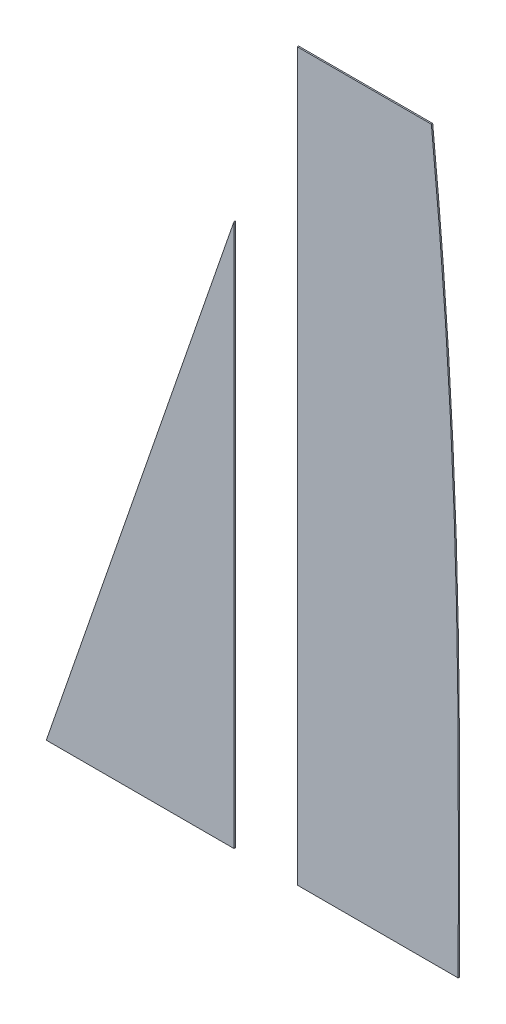
from build123d import *

# Parameters (mm, degrees)
BOSS_EXTRUDE1_DEPTH   = 2.54
BOSS_EXTRUDE1_2_DEPTH = 2.54


with BuildPart() as part:
    # Sketch1 → Boss-Extrude1 (new body)
    with BuildSketch(Plane.XY):
        Polygon((0, 0), (0, 1028.7), (-355.6, 0), align=None)
    extrude(amount=BOSS_EXTRUDE1_DEPTH)


with BuildPart() as body_2:
    # Sketch1 → Boss-Extrude1 2 (new body)
    with BuildSketch(Plane.XY):
        with BuildLine():
            Line((373.751491802, 1375.123958426), (119.751491802, 1375.123958426))
            Line((119.751491802, 1375.123958426), (119.751491802, 0))
            Line((119.751491802, 0), (424.551491802, 0))
            add(Edge.make_bspline(
                [(424.551491802, 0), (424.57285643, 401.777203165), (432.304675958, 795.435328411), (373.751491802, 1375.123958426)],
                knots=[0, 0, 0, 0, 1, 1, 1, 1], degree=3))
        make_face()
    extrude(amount=BOSS_EXTRUDE1_2_DEPTH)


solid = Compound([part.part, body_2.part])
